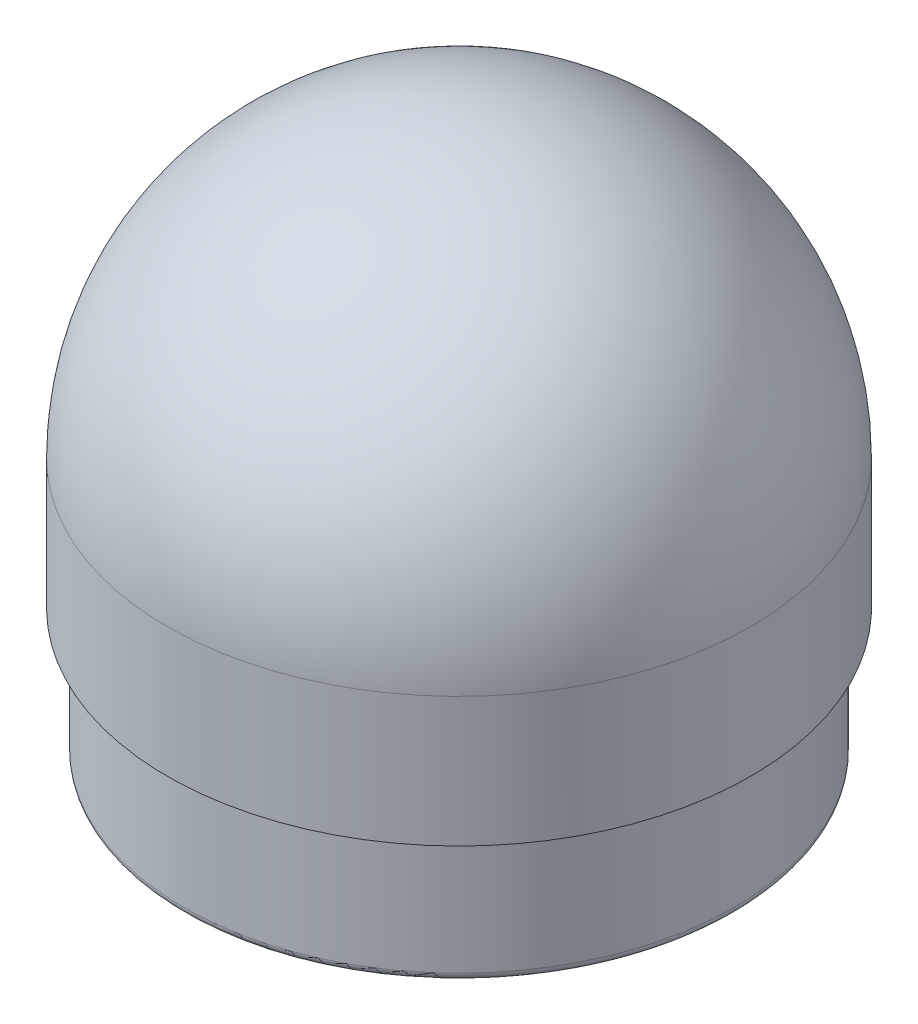
from build123d import *


with BuildPart() as part:
    # Sketch2 → Revolve1 (revolve)
    with BuildSketch(Plane.XY):
        with BuildLine():
            Line((47.625, 0), (52.3875, 0))
            ThreePointArc((52.3875, 0), (53.510032015, 0.464967985), (53.975, 1.5875))
            Line((53.975, 1.5875), (53.975, 25.4))
            Line((53.975, 25.4), (57.15, 25.4))
            Line((57.15, 25.4), (57.15, 50.8))
            ThreePointArc((57.15, 50.8), (40.411152545, 91.211152545), (0, 107.95))
            Line((0, 107.95), (0, 98.425))
            ThreePointArc((0, 98.425), (33.675960454, 84.475960454), (47.625, 50.8))
            Line((47.625, 50.8), (47.625, 0))
        make_face()
    revolve(axis=Axis((0, 98.425, 0), (0, 1, 0)))


solid = part.part
